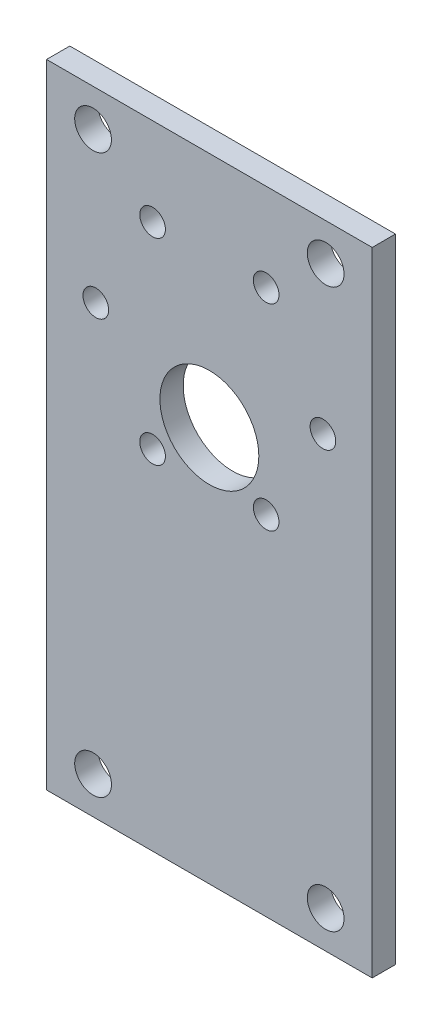
from build123d import *

# Parameters (mm, degrees)
SKETCH_1_R      = 1.75
SKETCH_1_R_2    = 6.75
SKETCH_1_R_3    = 2.50825
EXTRUDE_1_DEPTH = 3.175


with BuildPart() as part:
    # Эскиз1 → Бобышка-Вытянуть1 (new body)
    with BuildSketch(Plane.XY):
        Polygon((-82.246241796, 78.484271146), (-126.696241796, 78.484271146), (-126.696241796, 27.684271146), (-126.696241796, -7.875728854), (-82.246241796, -7.875728854), (-82.246241796, 27.684271146), align=None)
        with Locations((-112.221241796, 66.507664905)):
            Circle(SKETCH_1_R, mode=Mode.SUBTRACT)
        with Locations((-119.971241796, 53.084271146)):
            Circle(SKETCH_1_R, mode=Mode.SUBTRACT)
        with Locations((-112.221241796, 39.660877387)):
            Circle(SKETCH_1_R, mode=Mode.SUBTRACT)
        with Locations((-96.721241796, 39.660877387)):
            Circle(SKETCH_1_R, mode=Mode.SUBTRACT)
        with Locations((-88.971241796, 53.084271146)):
            Circle(SKETCH_1_R, mode=Mode.SUBTRACT)
        with Locations((-96.721241796, 66.507664905)):
            Circle(SKETCH_1_R, mode=Mode.SUBTRACT)
        with Locations((-104.471241796, 46.084259746)):
            Circle(SKETCH_1_R_2, mode=Mode.SUBTRACT)
        with Locations((-88.596241796, 73.404271146)):
            Circle(SKETCH_1_R_3, mode=Mode.SUBTRACT)
        with Locations((-120.346241796, 73.404271146)):
            Circle(SKETCH_1_R_3, mode=Mode.SUBTRACT)
        with Locations((-88.596241796, -2.795728854)):
            Circle(SKETCH_1_R_3, mode=Mode.SUBTRACT)
        with Locations((-120.346241796, -2.795728854)):
            Circle(SKETCH_1_R_3, mode=Mode.SUBTRACT)
    extrude(amount=EXTRUDE_1_DEPTH)


solid = part.part
